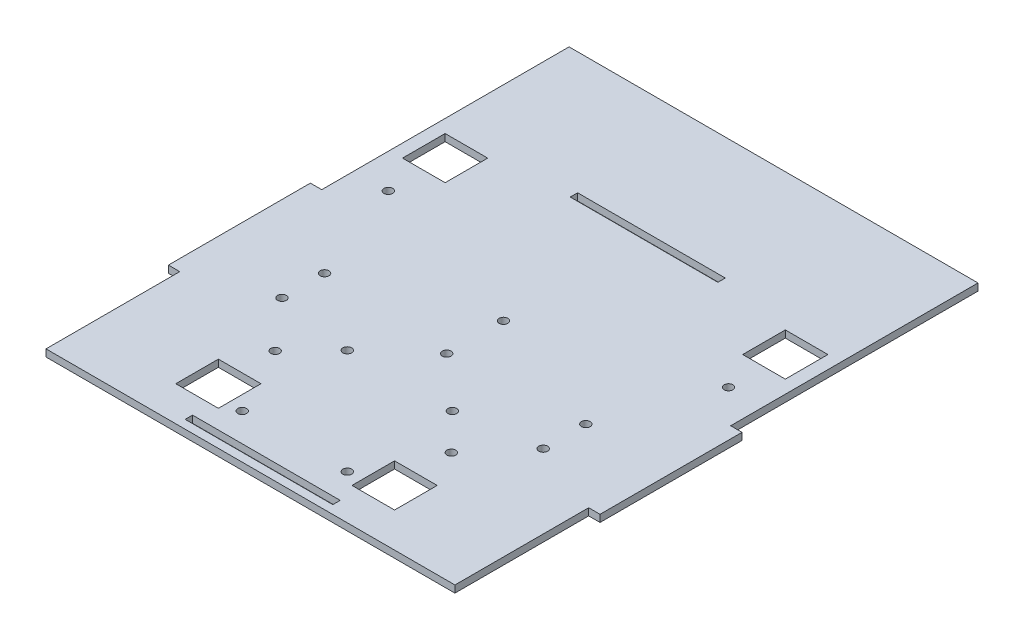
from build123d import *

# Parameters (mm, degrees)
SKETCH1_R           = 1.55
SKETCH1_W           = 15
SKETCH1_H           = 15
SKETCH1_W_2         = 52
SKETCH1_H_2         = 2.6
BOSS_EXTRUDE1_DEPTH = 2.5
SKETCH2_W           = 144
SKETCH2_H           = 40
BOSS_EXTRUDE2_DEPTH = 2.5


with BuildPart() as part:
    # Sketch1 → Boss-Extrude1 (new body)
    with BuildSketch(Plane(origin=(0, 0, 0), x_dir=(1, 0, 0), z_dir=(0, 1, 0))):
        Polygon((-72, -25), (-76, -25), (-76, 25), (-72, 25), (-72, 72.1), (72, 72.1), (72, 25), (76, 25), (76, -25), (72, -25), (72, -72.1), (-72, -72.1), align=None)
        with Locations((-18.5, -56.5)):
            Circle(SKETCH1_R, mode=Mode.SUBTRACT)
        with Locations((-18.5, -19.5)):
            Circle(SKETCH1_R, mode=Mode.SUBTRACT)
        with Locations((18.5, -19.5)):
            Circle(SKETCH1_R, mode=Mode.SUBTRACT)
        with Locations((18.5, -56.5)):
            Circle(SKETCH1_R, mode=Mode.SUBTRACT)
        with Locations((0, -3)):
            Circle(SKETCH1_R, mode=Mode.SUBTRACT)
        with Locations((0, 17)):
            Circle(SKETCH1_R, mode=Mode.SUBTRACT)
        with Locations((-59.898406921, 36.347928242)):
            Circle(SKETCH1_R, mode=Mode.SUBTRACT)
        with Locations((59.898406921, 36.347928242)):
            Circle(SKETCH1_R, mode=Mode.SUBTRACT)
        with Locations((31.018932052, -32.377895768)):
            Circle(SKETCH1_R, mode=Mode.SUBTRACT)
        with Locations((-31.018932052, -32.377895768)):
            Circle(SKETCH1_R, mode=Mode.SUBTRACT)
        with Locations((-46, -15)):
            Circle(SKETCH1_R, mode=Mode.SUBTRACT)
        with Locations((-46, 0)):
            Circle(SKETCH1_R, mode=Mode.SUBTRACT)
        with Locations((46, -15)):
            Circle(SKETCH1_R, mode=Mode.SUBTRACT)
        with Locations((46, 0)):
            Circle(SKETCH1_R, mode=Mode.SUBTRACT)
        with Locations((59.898406921, 56.347928242)):
            Rectangle(SKETCH1_W, SKETCH1_H, mode=Mode.SUBTRACT)
        with Locations((-59.898406921, 56.347928242)):
            Rectangle(SKETCH1_W, SKETCH1_H, mode=Mode.SUBTRACT)
        with Locations((31.018932052, -52.377895768)):
            Rectangle(SKETCH1_W, SKETCH1_H, mode=Mode.SUBTRACT)
        with Locations((-31.018932052, -52.377895768)):
            Rectangle(SKETCH1_W, SKETCH1_H, mode=Mode.SUBTRACT)
        with Locations((0, -67.8)):
            Rectangle(SKETCH1_W_2, SKETCH1_H_2, mode=Mode.SUBTRACT)
        with Locations((0, 67.8)):
            Rectangle(SKETCH1_W_2, SKETCH1_H_2, mode=Mode.SUBTRACT)
    extrude(amount=BOSS_EXTRUDE1_DEPTH)

    # Sketch2 → Boss-Extrude2 (add)
    with BuildSketch(Plane(origin=(0, 2.5, 0), x_dir=(1, 0, 0), z_dir=(0, 1, 0))):
        with Locations((0, 92.1)):
            Rectangle(SKETCH2_W, SKETCH2_H)
    extrude(amount=-BOSS_EXTRUDE2_DEPTH)


solid = part.part
